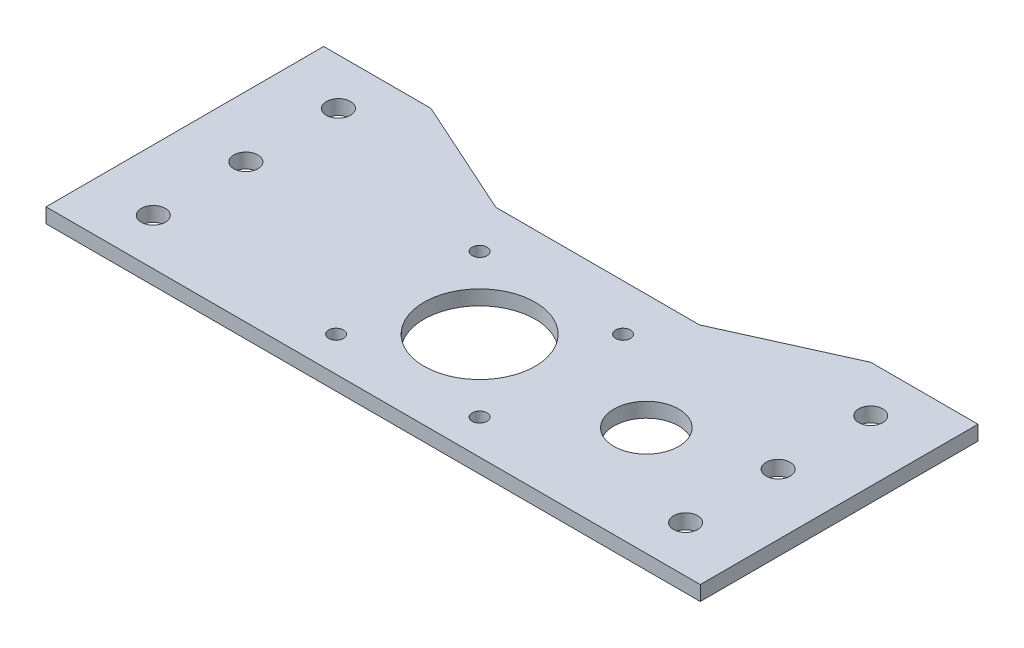
from build123d import *

# Parameters (mm, degrees)
SKETCH2_R           = 2.6
SKETCH2_R_2         = 12
SKETCH2_R_3         = 1.6
SKETCH2_R_4         = 7
BOSS_EXTRUDE1_DEPTH = 3.175


with BuildPart() as part:
    # Sketch2 → Boss-Extrude1 (new body)
    with BuildSketch(Plane(origin=(0, 0, 0), x_dir=(1, 0, 0), z_dir=(0, 1, 0))):
        Polygon((70.675, 0), (-70.675, 0), (-70.675, 60), (-47.5, 60), (-22, 48.5), (22, 48.5), (47.5, 60), (70.675, 60), align=None)
        with Locations((-57.5, 30)):
            Circle(SKETCH2_R, mode=Mode.SUBTRACT)
        with Locations((-57.5, 50)):
            Circle(SKETCH2_R, mode=Mode.SUBTRACT)
        with Locations((-57.5, 10)):
            Circle(SKETCH2_R, mode=Mode.SUBTRACT)
        with Locations((0, 23)):
            Circle(SKETCH2_R_2, mode=Mode.SUBTRACT)
        with Locations((-15.5, 38.5)):
            Circle(SKETCH2_R_3, mode=Mode.SUBTRACT)
        with Locations((15.5, 38.5)):
            Circle(SKETCH2_R_3, mode=Mode.SUBTRACT)
        with Locations((15.5, 7.5)):
            Circle(SKETCH2_R_3, mode=Mode.SUBTRACT)
        with Locations((-15.5, 7.5)):
            Circle(SKETCH2_R_3, mode=Mode.SUBTRACT)
        with Locations((57.5, 10)):
            Circle(SKETCH2_R, mode=Mode.SUBTRACT)
        with Locations((57.5, 30)):
            Circle(SKETCH2_R, mode=Mode.SUBTRACT)
        with Locations((57.5, 50)):
            Circle(SKETCH2_R, mode=Mode.SUBTRACT)
        with Locations((35.5, 23.525)):
            Circle(SKETCH2_R_4, mode=Mode.SUBTRACT)
    extrude(amount=BOSS_EXTRUDE1_DEPTH)


solid = part.part
